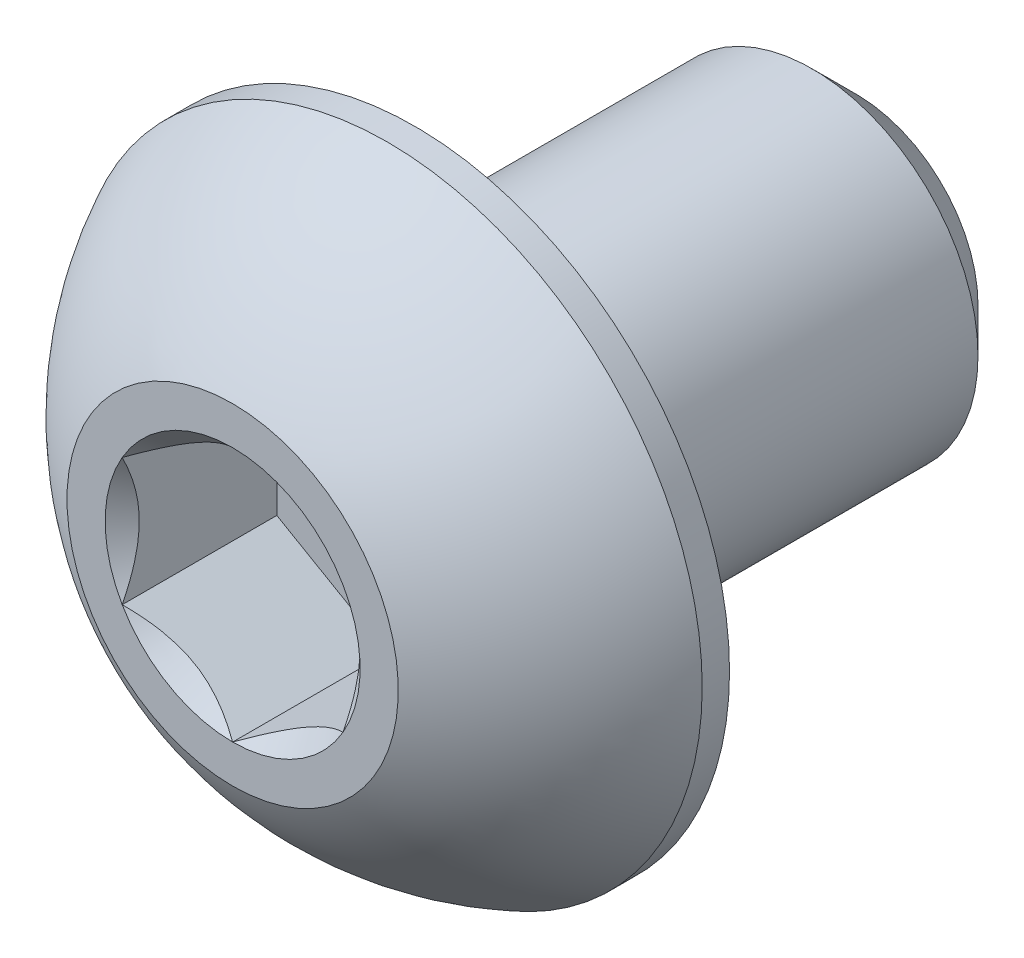
from build123d import *

# Parameters (mm, degrees)
CUT_EXTRUDE1_DEPTH = 1.4


with BuildPart() as part:
    # Sketch2 → Revolve1 (revolve)
    with BuildSketch(Plane(origin=(0, 0, 0), x_dir=(0, 0, -1), z_dir=(1, 0, 0)), mode=Mode.PRIVATE) as revolve1_sk:
        with BuildLine():
            Line((-2.825, 0), (2.825, 0))
            Line((2.825, 0), (2.825, 1.1))
            Line((2.825, 1.1), (2.425, 1.5))
            Line((2.425, 1.5), (-1.175, 1.5))
            Line((-1.175, 1.5), (-1.175, 2.85))
            Line((-1.175, 2.85), (-1.4225, 2.85))
            ThreePointArc((-1.4225, 2.85), (-2.22987489, 2.285251969), (-2.825, 1.5))
            Line((-2.825, 1.5), (-2.825, 0))
        make_face()
    revolve(revolve1_sk.sketch.rotate(Axis((0, 0, 2.825), (0, 0, -1)), 90), axis=Axis((0, 0, 2.825), (0, 0, -1)))

    # Sketch3 → Cut-Extrude1 (cut)
    with BuildSketch(Plane.XY.offset(2.825)):
        Polygon((0, 1.154700538), (-1, 0.577350269), (-1, -0.577350269), (0, -1.154700538), (1, -0.577350269), (1, 0.577350269), align=None)
    extrude(amount=-CUT_EXTRUDE1_DEPTH, mode=Mode.SUBTRACT)

    # Cut-Extrude2 cone 1 section (through the dimple's axis) → Cut-Extrude2 (revolve, cut)
    with BuildSketch(Plane(origin=(0, 0, 2.825), x_dir=(0, -1, 0), z_dir=(1, 0, 0))):
        Polygon((0, 0), (1.154700538, 0), (0, 1.154700538), align=None)
    revolve(axis=Axis((0, 0, 2.825), (0, 0, -1)), mode=Mode.SUBTRACT)


solid = part.part
